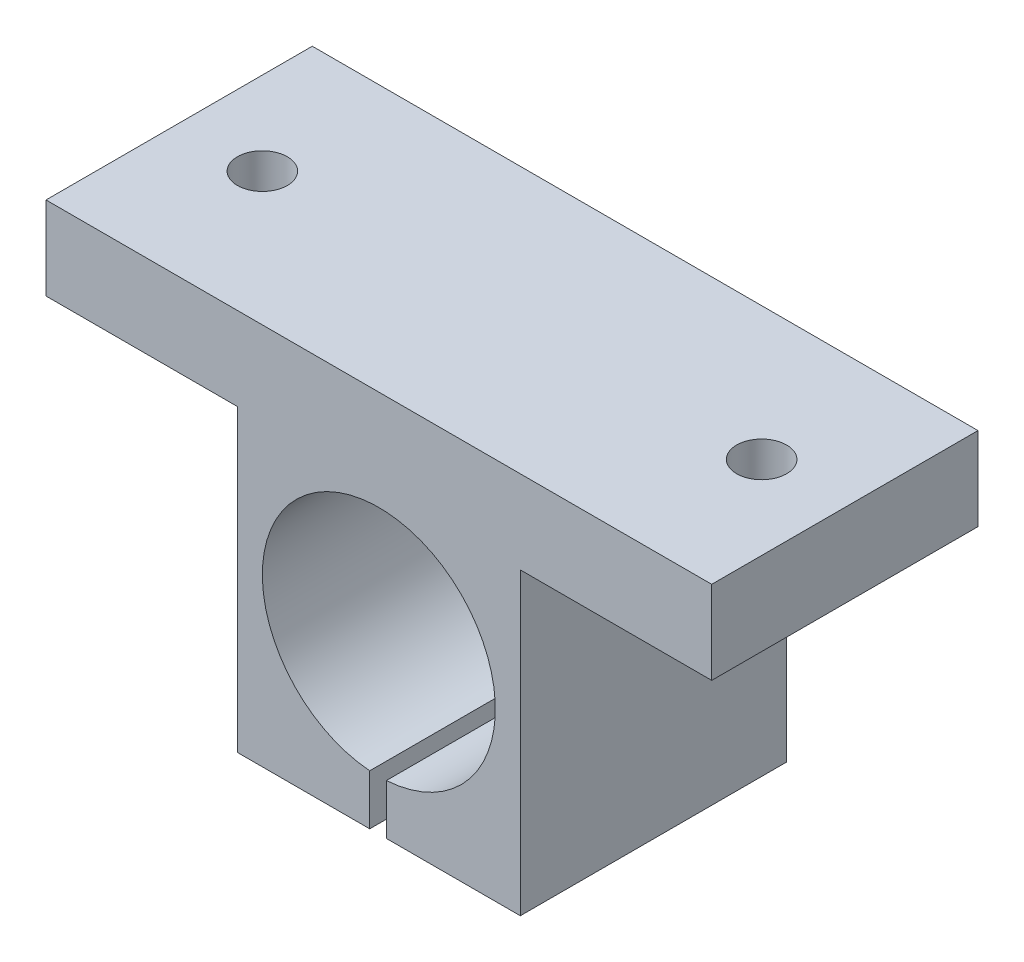
from build123d import *

# Parameters (mm, degrees)
ESBO_O1_R                = 7
RESSALTO_EXTRUS_O1_DEPTH = 16
ESBO_O2_W                = 1
ESBO_O2_H                = 5.647679103
CORTE_EXTRUS_O1_DEPTH    = 17
ESBO_O3_R                = 1.5
CORTE_EXTRUS_O2_DEPTH    = 16


with BuildPart() as part:
    # Esboço1 → Ressalto-extrusão1 (new body)
    with BuildSketch(Plane.XY):
        Polygon((-20, 8), (-8.5, 8), (-8.5, -10), (8.5, -10), (8.5, 8), (20, 8), (20, 13), (-20, 13), align=None)
        Circle(ESBO_O1_R, mode=Mode.SUBTRACT)
    extrude(amount=RESSALTO_EXTRUS_O1_DEPTH)

    # Esboço2 → Corte-extrusão1 (cut, through all)
    with BuildSketch(Plane.XY.offset(16)):
        with Locations((-0.048670763, -9.044181363)):
            Rectangle(ESBO_O2_W, ESBO_O2_H)
    extrude(amount=-CORTE_EXTRUS_O1_DEPTH, mode=Mode.SUBTRACT)

    # Esboço3 → Corte-extrusão2 (cut)
    with BuildSketch(Plane.XZ.offset(-8)):
        with Locations((-15, 8)):
            Circle(ESBO_O3_R)
    corte_extrus_o2 = extrude(amount=-CORTE_EXTRUS_O2_DEPTH, mode=Mode.SUBTRACT)

    # Espelhar1: Corte-extrusão2 across plane
    add(corte_extrus_o2.mirror(Plane(origin=(0, 0, 0), x_dir=(0, 0, 1), z_dir=(1, 0, 0))), mode=Mode.SUBTRACT)


solid = part.part
